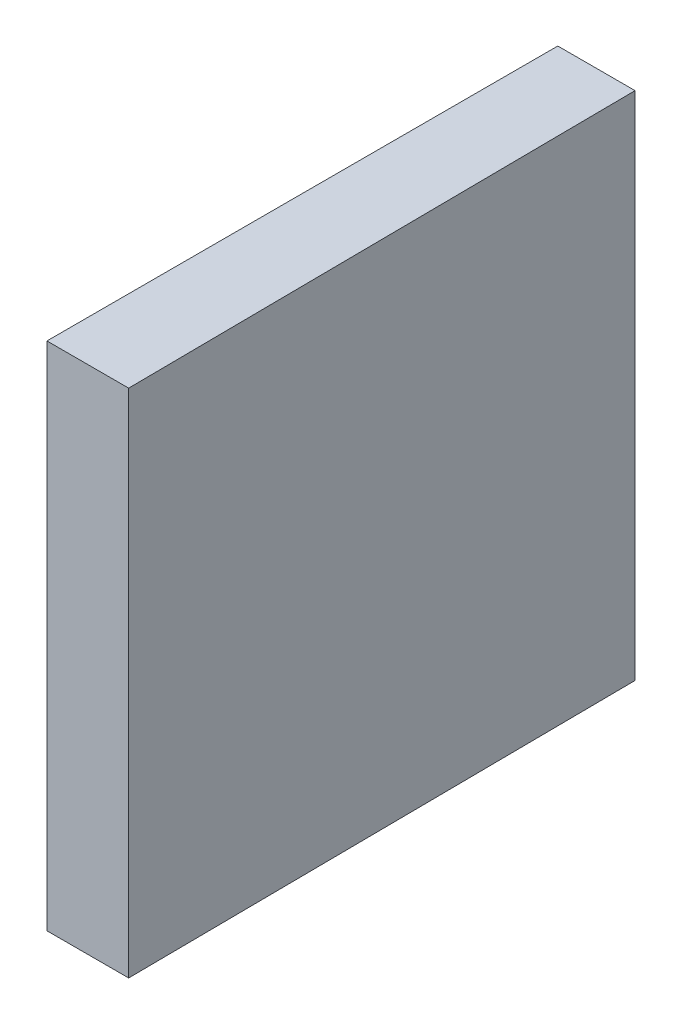
from build123d import *

# Parameters (mm, degrees)
EXTRUDE_1_DEPTH = 50


with BuildPart() as part:
    # 草图1 → 凸台-拉伸1 (new body)
    with BuildSketch(Plane(origin=(0, 0, 0), x_dir=(1, 0, 0), z_dir=(0, 1, 0))):
        Polygon((0, 25), (0, -25), (8, -25), (7.56365661, 25), align=None)
    extrude(amount=EXTRUDE_1_DEPTH)


solid = part.part
